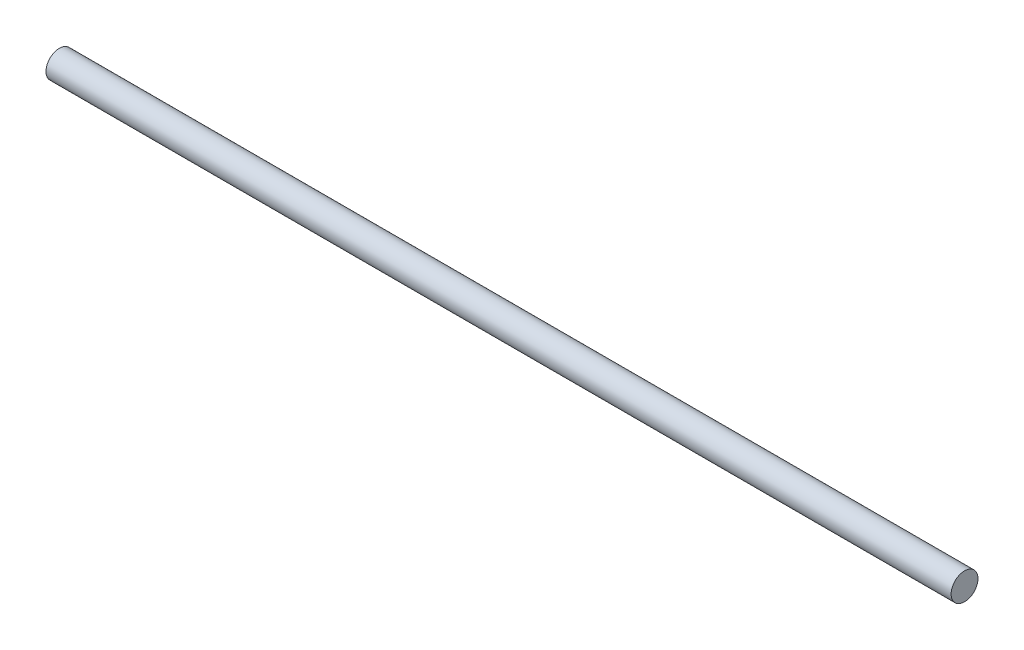
from build123d import *

# Parameters (mm, degrees)
SKETCH1_R           = 2.375
BOSS_EXTRUDE1_DEPTH = 160


with BuildPart() as part:
    # Sketch1 → Boss-Extrude1 (new body)
    with BuildSketch(Plane(origin=(0, 0, 0), x_dir=(0, 0, -1), z_dir=(1, 0, 0))):
        Circle(SKETCH1_R)
    extrude(amount=BOSS_EXTRUDE1_DEPTH)


solid = part.part
